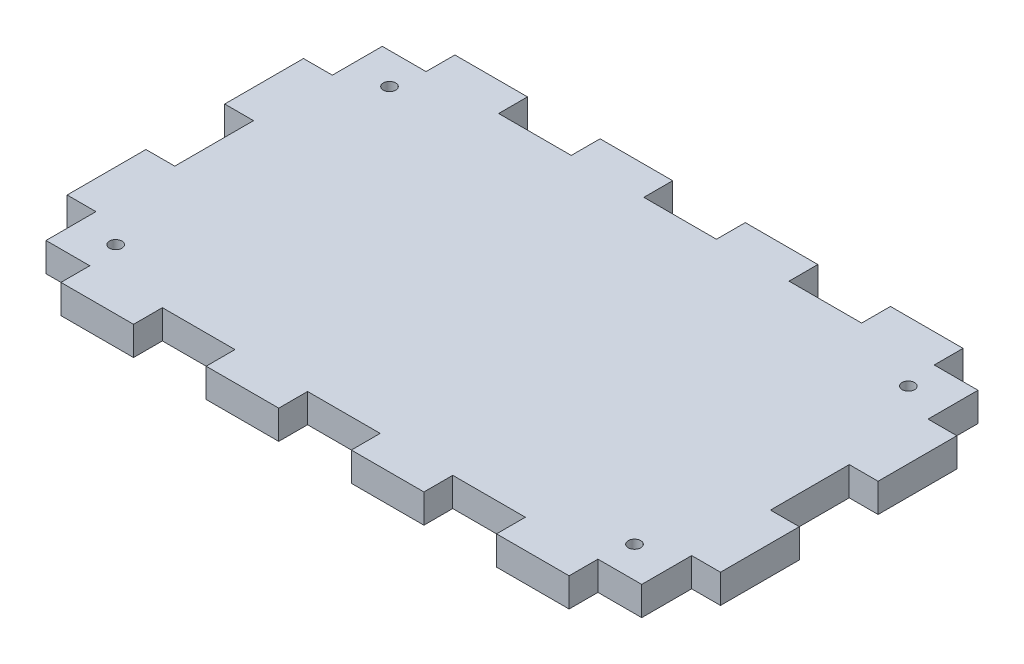
from build123d import *

# Parameters (mm, degrees)
AUFSATZ_LINEAR_AUSTRAGEN1_DEPTH = 3
SCHNITT_LINEAR_AUSTRAGEN1_REACH = 5
SKIZZE2_R                       = 0.65


with BuildPart() as part:
    # Skizze1 → Aufsatz-Linear austragen1 (new body)
    with BuildSketch(Plane(origin=(0, 0, 0), x_dir=(1, 0, 0), z_dir=(0, 1, 0))):
        Polygon((2.999994, 37.999416), (2.999994, 32.800036), (0, 32.800036), (0, 24.599138), (2.999994, 24.599138), (2.999994, 16.399764), (0, 16.399764), (0, 8.19912), (2.999994, 8.19912), (2.999994, 2.999994), (7.555738, 2.999994), (7.555738, 0), (15.11173, 0), (15.11173, 2.999994), (22.667468, 2.999994), (22.667468, 0), (30.223206, 0), (30.223206, 2.999994), (37.778944, 2.999994), (37.778944, 0), (45.333412, 0), (45.333412, 2.999994), (52.88915, 2.999994), (52.88915, 0), (60.444888, 0), (60.444888, 2.999994), (65.000632, 2.999994), (65.000632, 8.19912), (68.00088, 8.19912), (68.00088, 16.399764), (65.000632, 16.399764), (65.000632, 24.599138), (68.00088, 24.599138), (68.00088, 32.800036), (65.000632, 32.800036), (65.000632, 37.999416), (60.444888, 37.999416), (60.444888, 40.99941), (52.88915, 40.99941), (52.88915, 37.999416), (45.333412, 37.999416), (45.333412, 40.99941), (37.778944, 40.99941), (37.778944, 37.999416), (30.223206, 37.999416), (30.223206, 40.99941), (22.667468, 40.99941), (22.667468, 37.999416), (15.11173, 37.999416), (15.11173, 40.99941), (7.555738, 40.99941), (7.555738, 37.999416), align=None)
    extrude(amount=AUFSATZ_LINEAR_AUSTRAGEN1_DEPTH)

    # Skizze2 → Schnitt-Linear austragen1 (cut, up to next)
    with BuildSketch(Plane(origin=(0, 3, 0), x_dir=(1, 0, 0), z_dir=(0, 1, 0)), mode=Mode.PRIVATE) as schnitt_linear_austragen1_sk1:
        with Locations((7.001075, 34.749451)):
            Circle(SKIZZE2_R)
    schnitt_linear_austragen1_tool1 = extrude(schnitt_linear_austragen1_sk1.sketch, amount=-SCHNITT_LINEAR_AUSTRAGEN1_REACH, mode=Mode.PRIVATE) & part.part
    add(schnitt_linear_austragen1_tool1.solids().sort_by_distance((7.001075, 3, -34.749451))[0], mode=Mode.SUBTRACT)
    # Skizze2 → Schnitt-Linear austragen1 (cut, up to next)
    with BuildSketch(Plane(origin=(0, 3, 0), x_dir=(1, 0, 0), z_dir=(0, 1, 0)), mode=Mode.PRIVATE) as schnitt_linear_austragen1_sk2:
        with Locations((61.001075, 34.749451)):
            Circle(SKIZZE2_R)
    schnitt_linear_austragen1_tool2 = extrude(schnitt_linear_austragen1_sk2.sketch, amount=-SCHNITT_LINEAR_AUSTRAGEN1_REACH, mode=Mode.PRIVATE) & part.part
    add(schnitt_linear_austragen1_tool2.solids().sort_by_distance((61.001075, 3, -34.749451))[0], mode=Mode.SUBTRACT)
    # Skizze2 → Schnitt-Linear austragen1 (cut, up to next)
    with BuildSketch(Plane(origin=(0, 3, 0), x_dir=(1, 0, 0), z_dir=(0, 1, 0)), mode=Mode.PRIVATE) as schnitt_linear_austragen1_sk3:
        with Locations((61.001075, 6.249451)):
            Circle(SKIZZE2_R)
    schnitt_linear_austragen1_tool3 = extrude(schnitt_linear_austragen1_sk3.sketch, amount=-SCHNITT_LINEAR_AUSTRAGEN1_REACH, mode=Mode.PRIVATE) & part.part
    add(schnitt_linear_austragen1_tool3.solids().sort_by_distance((61.001075, 3, -6.249451))[0], mode=Mode.SUBTRACT)
    # Skizze2 → Schnitt-Linear austragen1 (cut, up to next)
    with BuildSketch(Plane(origin=(0, 3, 0), x_dir=(1, 0, 0), z_dir=(0, 1, 0)), mode=Mode.PRIVATE) as schnitt_linear_austragen1_sk4:
        with Locations((7.001075, 6.249451)):
            Circle(SKIZZE2_R)
    schnitt_linear_austragen1_tool4 = extrude(schnitt_linear_austragen1_sk4.sketch, amount=-SCHNITT_LINEAR_AUSTRAGEN1_REACH, mode=Mode.PRIVATE) & part.part
    add(schnitt_linear_austragen1_tool4.solids().sort_by_distance((7.001075, 3, -6.249451))[0], mode=Mode.SUBTRACT)


solid = part.part
